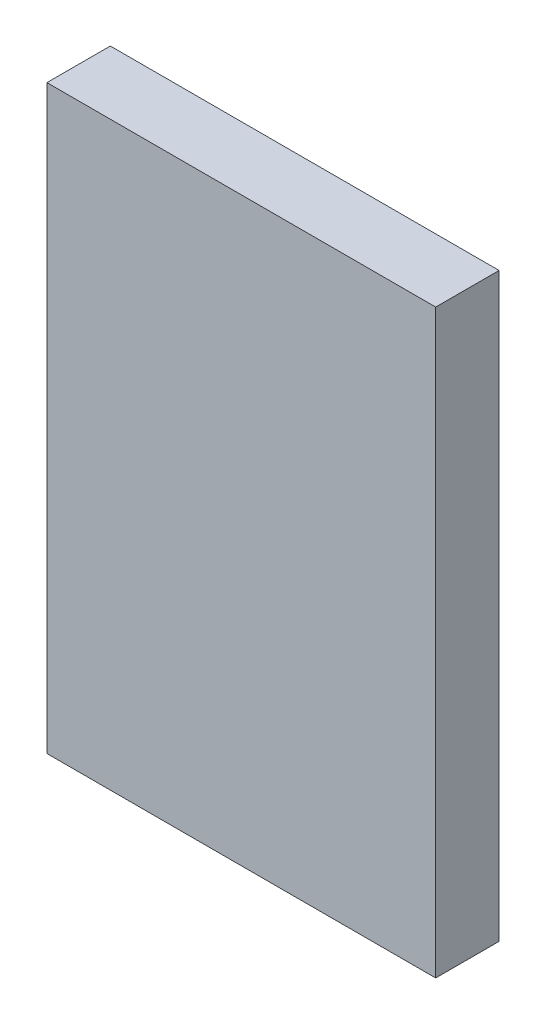
from build123d import *

# Parameters (mm, degrees)
SKETCH1_W           = 55.2
SKETCH1_H           = 82.5
BOSS_EXTRUDE1_DEPTH = 9


with BuildPart() as part:
    # Sketch1 → Boss-Extrude1 (new body)
    with BuildSketch(Plane.XY):
        Rectangle(SKETCH1_W, SKETCH1_H)
    extrude(amount=BOSS_EXTRUDE1_DEPTH)


solid = part.part
